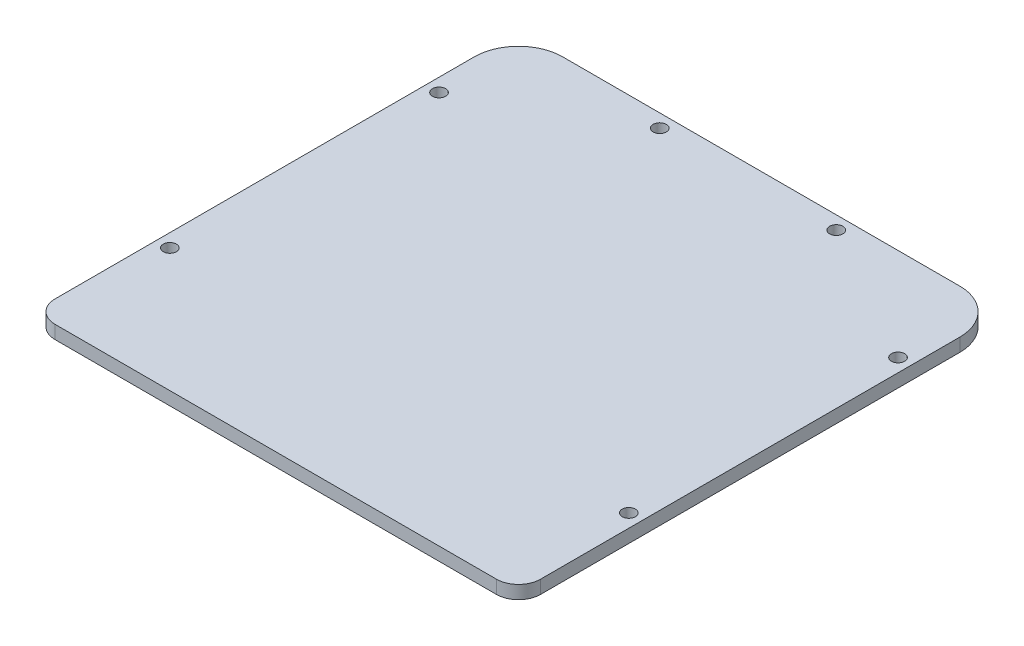
from build123d import *

# Parameters (mm, degrees)
BOSS_EXTRUDE1_DEPTH = 3
SKETCH2_R           = 1.5
CUT_EXTRUDE1_DEPTH  = 3


with BuildPart() as part:
    # Sketch1 → Boss-Extrude1 (new body)
    with BuildSketch(Plane(origin=(0, -220.619565514, 0), x_dir=(1, 0, 0), z_dir=(0, 1, 0))):
        with BuildLine():
            Line((-49.635107582, 293.830274817), (40.364892418, 293.830274817))
            ThreePointArc((40.364892418, 293.830274817), (47.435960229, 290.901342629), (50.364892418, 283.830274817))
            Line((50.364892418, 283.830274817), (50.364892418, 188.830274817))
            ThreePointArc((50.364892418, 188.830274817), (48.900426323, 185.294740911), (45.364892418, 183.830274817))
            Line((45.364892418, 183.830274817), (-54.635107582, 183.830274817))
            ThreePointArc((-54.635107582, 183.830274817), (-58.170641488, 185.294740911), (-59.635107582, 188.830274817))
            Line((-59.635107582, 188.830274817), (-59.635107582, 283.830274817))
            ThreePointArc((-59.635107582, 283.830274817), (-56.706175394, 290.901342629), (-49.635107582, 293.830274817))
        make_face()
    extrude(amount=BOSS_EXTRUDE1_DEPTH)

    # Sketch2 → Cut-Extrude1 (cut)
    with BuildSketch(Plane(origin=(0, -217.619565514, 0), x_dir=(1, 0, 0), z_dir=(0, 1, 0))):
        with Locations((-24.635107582, 290.833255232)):
            Circle(SKETCH2_R)
        with Locations((15.364892418, 290.833255232)):
            Circle(SKETCH2_R)
        with Locations((47.364892418, 272.830274817)):
            Circle(SKETCH2_R)
        with Locations((47.364892418, 211.830274817)):
            Circle(SKETCH2_R)
        with Locations((-56.635107582, 211.830274817)):
            Circle(SKETCH2_R)
        with Locations((-56.635107582, 272.830274817)):
            Circle(SKETCH2_R)
    extrude(amount=-CUT_EXTRUDE1_DEPTH, mode=Mode.SUBTRACT)


solid = part.part
